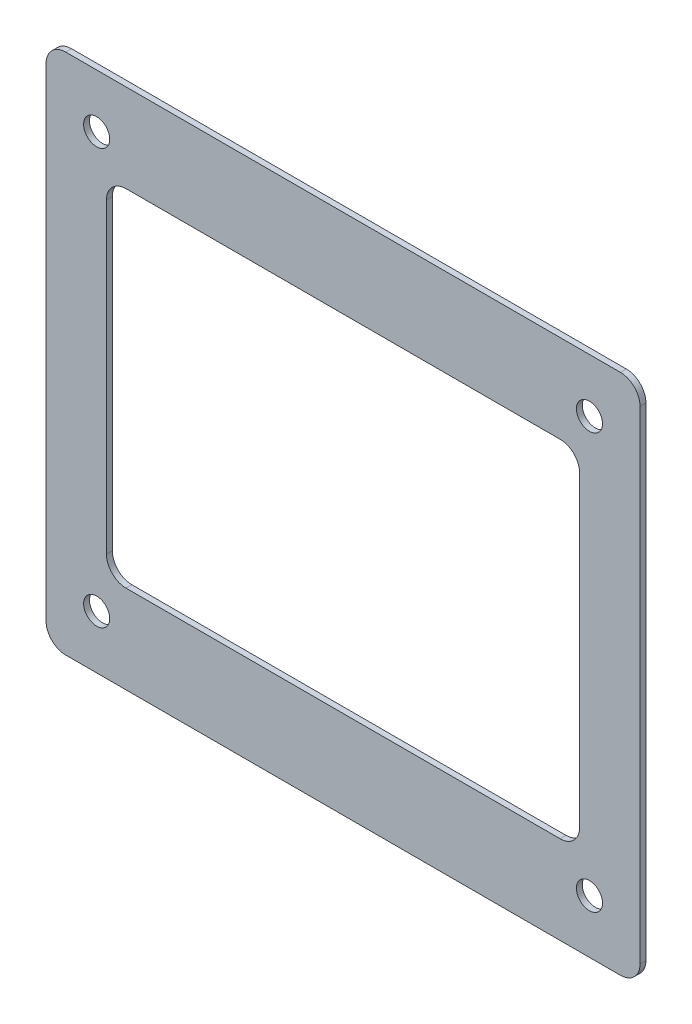
from build123d import *

# Parameters (mm, degrees)
CROQUIS1_R              = 2
SALIENTE_EXTRUIR1_DEPTH = 0.9


with BuildPart() as part:
    # Croquis1 → Saliente-Extruir1 (new body)
    with BuildSketch(Plane.XY):
        with BuildLine():
            Line((-45.323961465, 37.264057802), (-45.323961465, -36.735942198))
            ThreePointArc((-45.323961465, -36.735942198), (-44.445281809, -38.857262541), (-42.323961465, -39.735942198))
            Line((-42.323961465, -39.735942198), (42.676038535, -39.735942198))
            ThreePointArc((42.676038535, -39.735942198), (44.797358878, -38.857262541), (45.676038535, -36.735942198))
            Line((45.676038535, -36.735942198), (45.676038535, 37.264057802))
            ThreePointArc((45.676038535, 37.264057802), (44.797358878, 39.385378146), (42.676038535, 40.264057802))
            Line((42.676038535, 40.264057802), (-42.323961465, 40.264057802))
            ThreePointArc((-42.323961465, 40.264057802), (-44.445281809, 39.385378146), (-45.323961465, 37.264057802))
        make_face()
        with Locations((-37.573961465, 32.064057802)):
            Circle(CROQUIS1_R, mode=Mode.SUBTRACT)
        with Locations((37.926038535, 32.064057802)):
            Circle(CROQUIS1_R, mode=Mode.SUBTRACT)
        with Locations((37.926038535, -31.535942198)):
            Circle(CROQUIS1_R, mode=Mode.SUBTRACT)
        with Locations((-37.573961465, -31.535942198)):
            Circle(CROQUIS1_R, mode=Mode.SUBTRACT)
        with BuildLine():
            Line((-33.073961465, -26.235942198), (33.426038535, -26.235942198))
            ThreePointArc((33.426038535, -26.235942198), (35.547358878, -25.357262541), (36.426038535, -23.235942198))
            Line((36.426038535, -23.235942198), (36.426038535, 23.764057802))
            ThreePointArc((36.426038535, 23.764057802), (35.547358878, 25.885378146), (33.426038535, 26.764057802))
            Line((33.426038535, 26.764057802), (-33.073961465, 26.764057802))
            ThreePointArc((-33.073961465, 26.764057802), (-35.195281809, 25.885378146), (-36.073961465, 23.764057802))
            Line((-36.073961465, 23.764057802), (-36.073961465, -23.235942198))
            ThreePointArc((-36.073961465, -23.235942198), (-35.195281809, -25.357262541), (-33.073961465, -26.235942198))
        make_face(mode=Mode.SUBTRACT)
    extrude(amount=SALIENTE_EXTRUIR1_DEPTH)


solid = part.part
